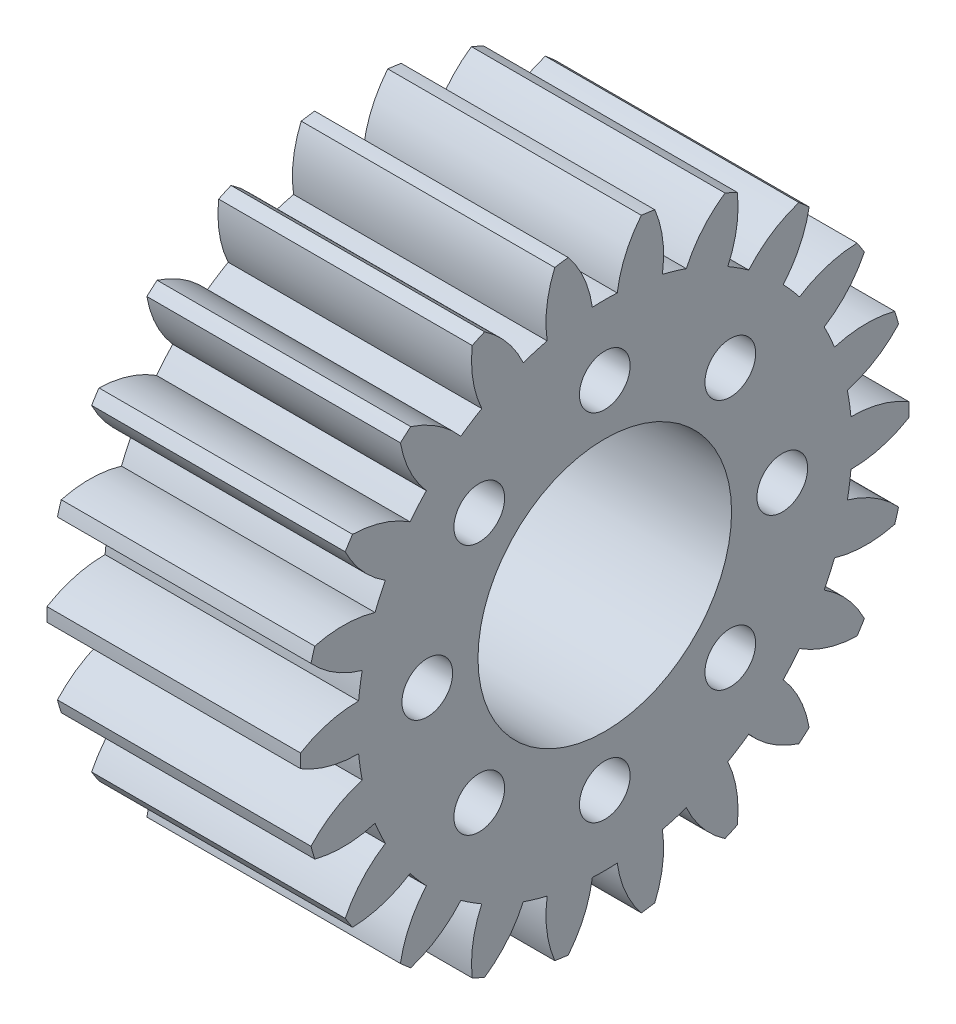
from build123d import *

# Parameters (mm, degrees)
BASPROSKE_W          = 10
BASPROSKE_H          = 12
TOOTHCUT_DEPTH       = 20.697715604
TEETHCUTS_COUNT      = 22
TEETHCUTS_ANGLE      = 343.636363636
BORSKE_R             = 5
BORE_DEPTH           = 50.0000508
D_GAGEMENT_M21_D     = 2
D_GAGEMENT_M21_DEPTH = 10


with BuildPart() as part:
    # BasProSke → Base-Revolve (revolve)
    with BuildSketch(Plane(origin=(0, 0, 0), x_dir=(1, 0, 0), z_dir=(0, 1, 0)), mode=Mode.PRIVATE) as base_revolve_sk:
        with Locations((5, 6)):
            Rectangle(BASPROSKE_W, BASPROSKE_H)
    revolve(base_revolve_sk.sketch.rotate(Axis((-10, 0, 0), (1, 0, 0)), 180), axis=Axis((-10, 0, 0), (1, 0, 0)))

    # TooCutSke → ToothCut (cut, through all)
    with BuildSketch(Plane(origin=(0, 0, 0), x_dir=(0, 0, -1), z_dir=(1, 0, 0))):
        with BuildLine():
            ThreePointArc((0.491001901, 9.736627657), (0, 9.749), (-0.491001901, 9.736627657))
            ThreePointArc((-0.491001901, 9.736627657), (-0.822824844, 10.904005344), (-1.46093845, 11.936327074))
            ThreePointArc((-1.46093845, 11.936327074), (0, 12.0254), (1.46093845, 11.936327074))
            ThreePointArc((1.46093845, 11.936327074), (0.822824844, 10.904005344), (0.491001901, 9.736627657))
        make_face()
    toothcut = extrude(amount=TOOTHCUT_DEPTH, mode=Mode.SUBTRACT)

    # TeethCuts: ToothCut ×22 about axis
    teethcuts_axis = Axis((-10, 0, 0), (1, 0, 0))
    for i in range(1, TEETHCUTS_COUNT):
        add(toothcut.rotate(teethcuts_axis, i * TEETHCUTS_ANGLE / (TEETHCUTS_COUNT - 1)), mode=Mode.SUBTRACT)

    # BorSke → Bore (cut, symmetric)
    with BuildSketch(Plane(origin=(0, 0, 0), x_dir=(0, 0, -1), z_dir=(1, 0, 0))):
        with Locations(Location((0, 0, 0), (0, 0, 180))):
            Circle(BORSKE_R)
    extrude(amount=BORE_DEPTH, both=True, mode=Mode.SUBTRACT)

    # Dégagement M21
    with Locations(Plane(origin=(10, 0, 0), x_dir=(0, 0, -1), z_dir=(1, 0, 0))):
        with Locations((0, 7), (4.949747468, 4.949747468), (7, 0), (4.949747468, -4.949747468), (0, -7), (-4.949747468, -4.949747468), (-7, 0), (-4.949747468, 4.949747468), (0, 0)):
            Hole(D_GAGEMENT_M21_D / 2, depth=D_GAGEMENT_M21_DEPTH)


solid = part.part
